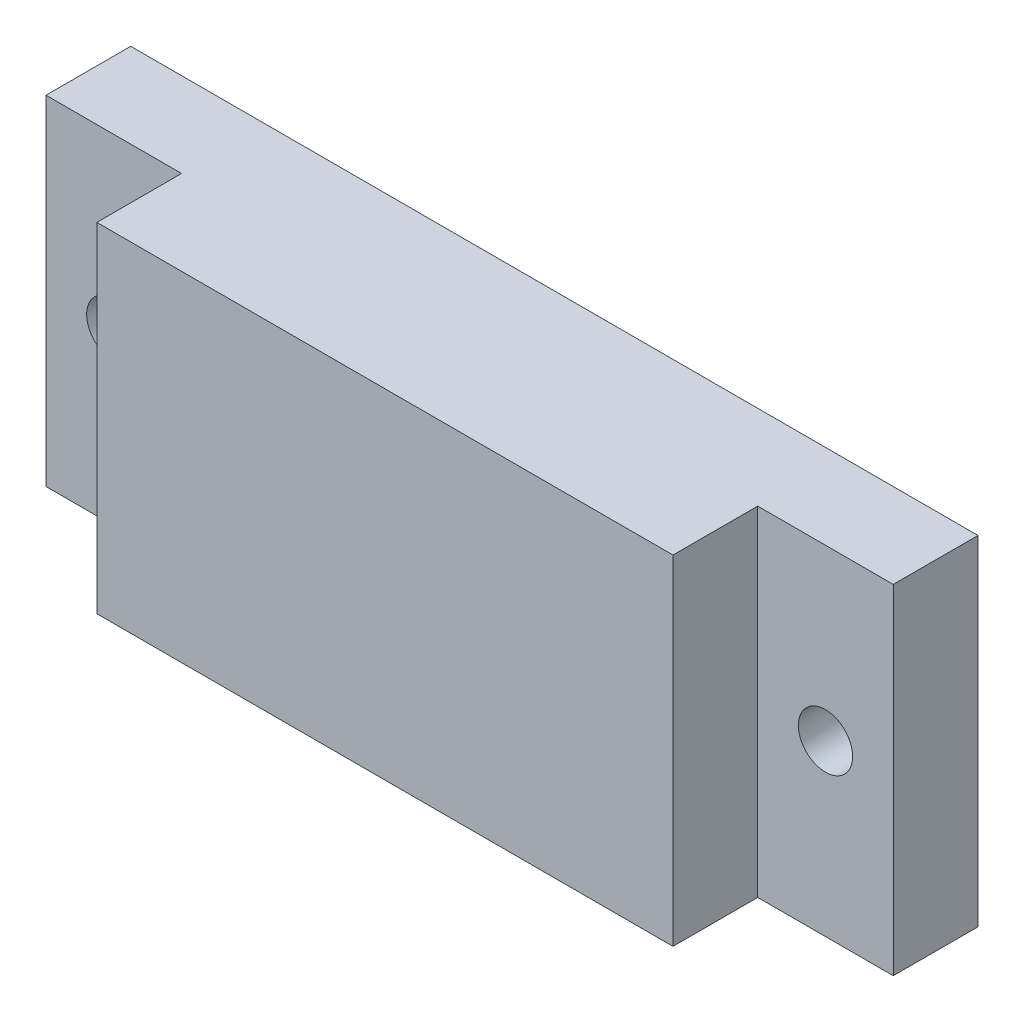
from build123d import *

# Parameters (mm, degrees)
SKETCH_1_W          = 50
SKETCH_1_H          = 20
EXTRUDE_1_DEPTH     = 5
SKETCH_2_W          = 34
SKETCH_2_H          = 20
EXTRUDE_2_DEPTH     = 5
SKETCH_3_R          = 1.6
CUT_EXTRUDE_1_DEPTH = 5


with BuildPart() as part:
    # 草图1 → 凸台-拉伸1 (new body)
    with BuildSketch(Plane.XY):
        with Locations((15.734265734, 15.34965035)):
            Rectangle(SKETCH_1_W, SKETCH_1_H)
    extrude(amount=EXTRUDE_1_DEPTH)

    # 草图2 → 凸台-拉伸2 (add)
    with BuildSketch(Plane.XY.offset(5)):
        with Locations((15.734265734, 15.34965035)):
            Rectangle(SKETCH_2_W, SKETCH_2_H)
    extrude(amount=EXTRUDE_2_DEPTH)

    # 草图3 → 切除-拉伸1 (cut)
    with BuildSketch(Plane.XY.offset(5)):
        with Locations((-5.265734266, 15.34965035)):
            Circle(SKETCH_3_R)
        with Locations((36.734265734, 15.34965035)):
            Circle(SKETCH_3_R)
    extrude(amount=-CUT_EXTRUDE_1_DEPTH, mode=Mode.SUBTRACT)


solid = part.part
